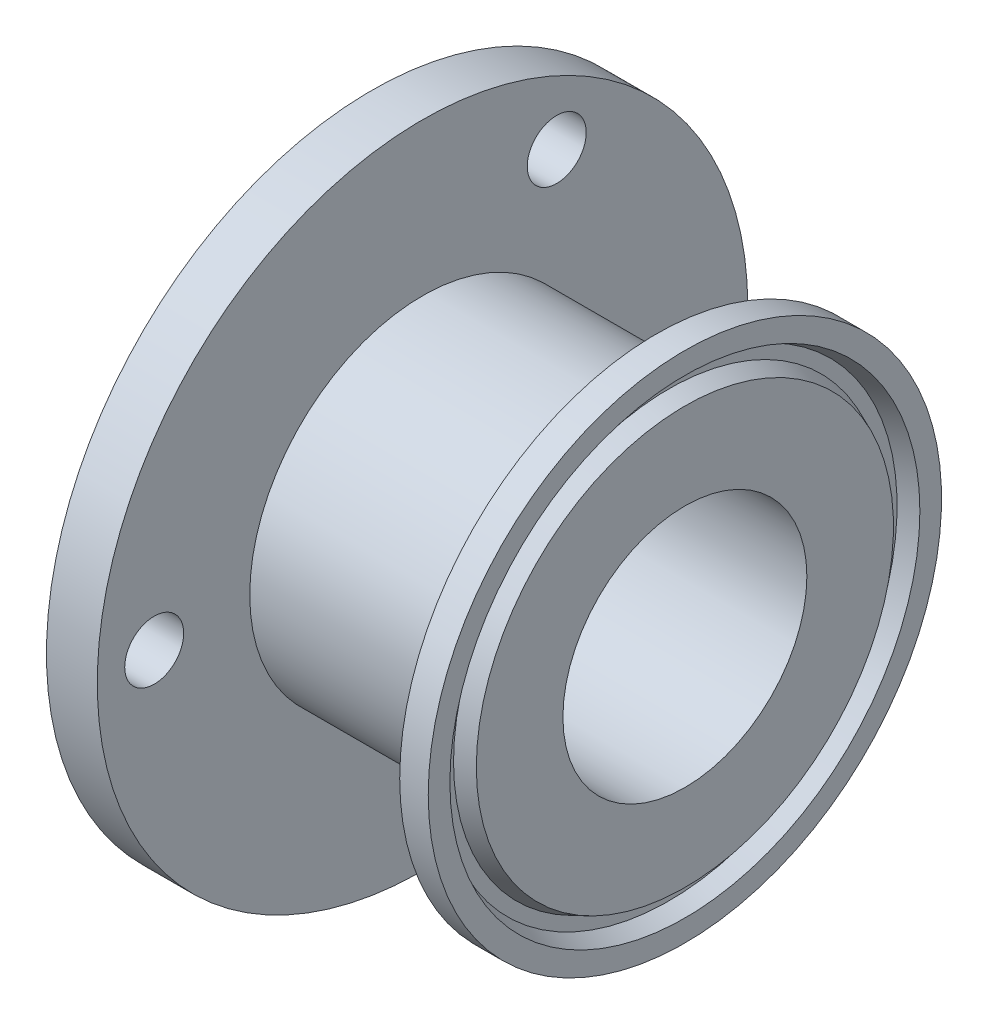
from build123d import *

# Parameters (mm, degrees)
M5_CLEARANCE_HOLE1_REACH  = 59.107
M5_CLEARANCE_HOLE1_BORE_R = 2.9
SKETCH5_R                 = 42
SKETCH5_R_2               = 32
CUT_EXTRUDE_THIN1_DEPTH   = 55.572226802


with BuildPart() as part:
    # Sketch1 → Revolve1 (revolve)
    with BuildSketch(Plane.XY, mode=Mode.PRIVATE) as revolve1_sk:
        with BuildLine():
            Line((-15.404727216, 12), (-15.404727216, 34))
            Line((-15.404727216, 34), (-10.404727216, 34))
            Line((-10.404727216, 34), (-10.404727216, 17))
            Line((-10.404727216, 17), (8.794935567, 17))
            ThreePointArc((8.794935567, 17), (9.450533434, 17.206709213), (9.869004233, 17.752070976))
            Line((9.869004233, 17.752070976), (12.598027216, 25.25))
            Line((12.598027216, 25.25), (15.404727216, 25.25))
            Line((15.404727216, 25.25), (15.404727216, 23.1186))
            Line((15.404727216, 23.1186), (13.829927216, 22.450137059))
            Line((13.829927216, 22.450137059), (13.829927216, 21.187062941))
            Line((13.829927216, 21.187062941), (15.404727216, 20.5186))
            Line((15.404727216, 20.5186), (15.404727216, 12))
            Line((15.404727216, 12), (-15.404727216, 12))
        make_face()
    revolve(revolve1_sk.sketch.rotate(Axis((0, 0, 0), (1, 0, 0)), 90), axis=Axis((0, 0, 0), (1, 0, 0)))

    # M5 Clearance Hole1 bore → M5 Clearance Hole1 (cut, up to next)
    with BuildSketch(Plane.ZY.offset(15.404727216), mode=Mode.PRIVATE) as m5_clearance_hole1_sk1:
        with Locations((-13.199999999, -22.86307066)):
            Circle(M5_CLEARANCE_HOLE1_BORE_R)
    m5_clearance_hole1_tool1 = extrude(m5_clearance_hole1_sk1.sketch, amount=-M5_CLEARANCE_HOLE1_REACH, mode=Mode.PRIVATE) & part.part
    # M5 Clearance Hole1 bore → M5 Clearance Hole1 (cut, up to next)
    with BuildSketch(Plane.ZY.offset(15.404727216), mode=Mode.PRIVATE) as m5_clearance_hole1_sk2:
        with Locations((-13.200000001, 22.863070659)):
            Circle(M5_CLEARANCE_HOLE1_BORE_R)
    m5_clearance_hole1_tool2 = extrude(m5_clearance_hole1_sk2.sketch, amount=-M5_CLEARANCE_HOLE1_REACH, mode=Mode.PRIVATE) & part.part
    # M5 Clearance Hole1 bore → M5 Clearance Hole1 (cut, up to next)
    with BuildSketch(Plane.ZY.offset(15.404727216), mode=Mode.PRIVATE) as m5_clearance_hole1_sk3:
        with Locations((26.4, 1e-09)):
            Circle(M5_CLEARANCE_HOLE1_BORE_R)
    m5_clearance_hole1_tool3 = extrude(m5_clearance_hole1_sk3.sketch, amount=-M5_CLEARANCE_HOLE1_REACH, mode=Mode.PRIVATE) & part.part
    add(m5_clearance_hole1_tool1.solids().sort_by_distance((-15.404727, -22.863071, -13.2))[0], mode=Mode.SUBTRACT)
    add(m5_clearance_hole1_tool2.solids().sort_by_distance((-15.404727, 22.863071, -13.2))[0], mode=Mode.SUBTRACT)
    add(m5_clearance_hole1_tool3.solids().sort_by_distance((-15.404727, 0, 26.4))[0], mode=Mode.SUBTRACT)

    # Sketch5 → Cut-Extrude-Thin1 (cut, through all)
    with BuildSketch(Plane(origin=(-10.404727216, 0, 0), x_dir=(0, 0, -1), z_dir=(1, 0, 0))):
        Circle(SKETCH5_R)
        Circle(SKETCH5_R_2, mode=Mode.SUBTRACT)
    extrude(amount=-CUT_EXTRUDE_THIN1_DEPTH, mode=Mode.SUBTRACT)


solid = part.part
